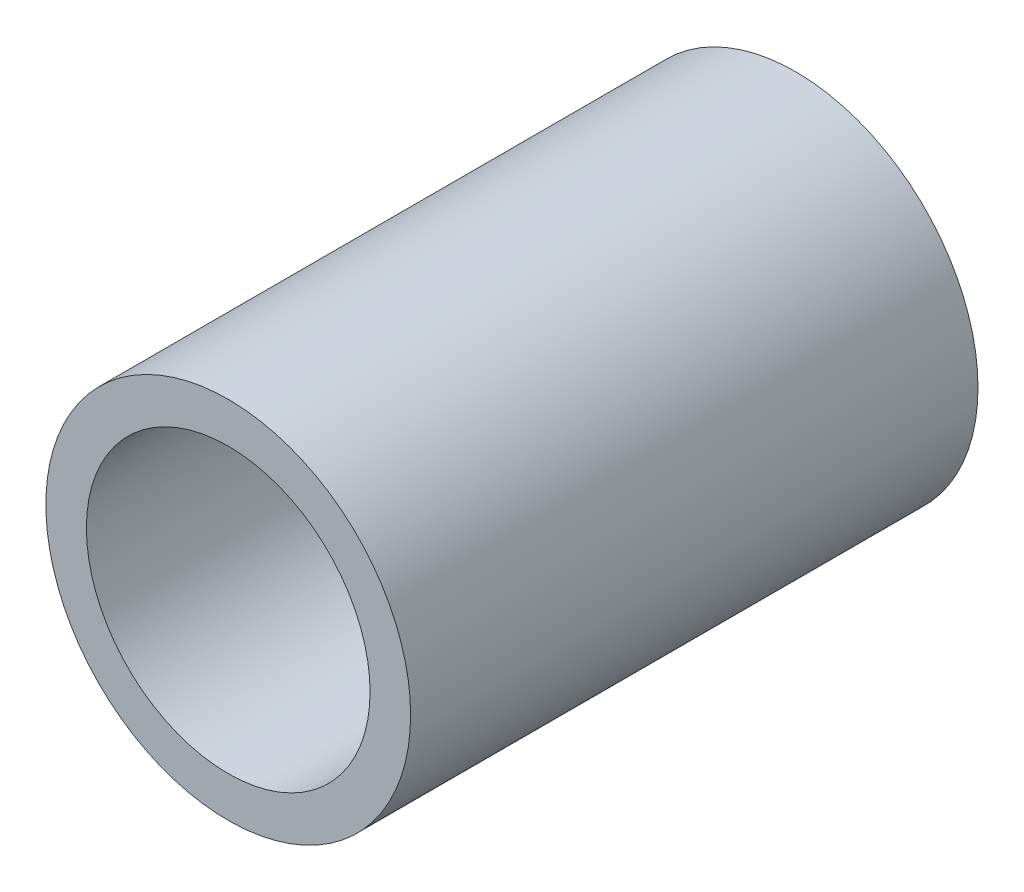
from build123d import *

# Parameters (mm, degrees)
SKETCH_1_R      = 2.25
SKETCH_1_R_2    = 1.75
EXTRUDE_1_DEPTH = 7


with BuildPart() as part:
    # 草图1 → 凸台-拉伸1 (new body)
    with BuildSketch(Plane.XY):
        Circle(SKETCH_1_R)
        Circle(SKETCH_1_R_2, mode=Mode.SUBTRACT)
    extrude(amount=EXTRUDE_1_DEPTH)


solid = part.part
